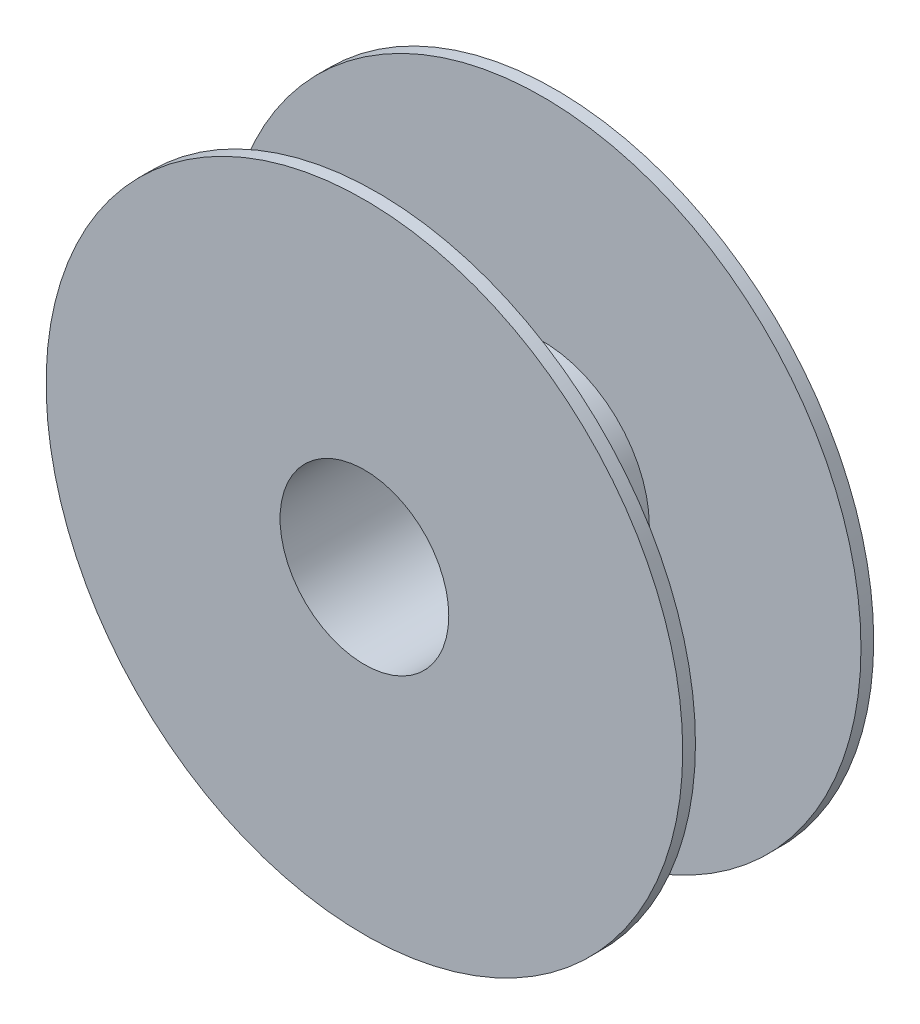
from build123d import *

# Parameters (mm, degrees)
SKETCH1_R           = 100
SKETCH1_R_2         = 26.5
BOSS_EXTRUDE1_DEPTH = 30
SKETCH2_R           = 100
SKETCH2_R_2         = 33.5
CUT_EXTRUDE1_DEPTH  = 26


with BuildPart() as part:
    # Sketch1 → Boss-Extrude1 (new body, symmetric)
    with BuildSketch(Plane.XY):
        Circle(SKETCH1_R)
        Circle(SKETCH1_R_2, mode=Mode.SUBTRACT)
    extrude(amount=BOSS_EXTRUDE1_DEPTH, both=True)

    # Sketch2 → Cut-Extrude1 (cut, symmetric)
    with BuildSketch(Plane.XY):
        Circle(SKETCH2_R)
        Circle(SKETCH2_R_2, mode=Mode.SUBTRACT)
    extrude(amount=CUT_EXTRUDE1_DEPTH, both=True, mode=Mode.SUBTRACT)


solid = part.part
